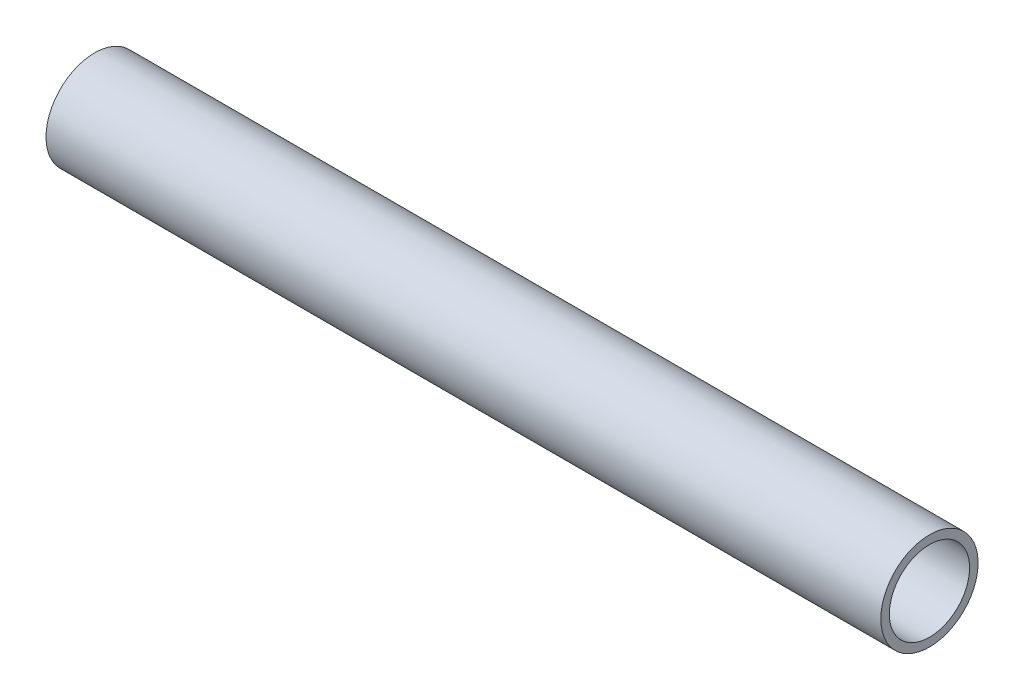
from build123d import *

# Parameters (mm, degrees)
SKETCH1_W = 361.95
SKETCH1_H = 3.683


with BuildPart() as part:
    # Sketch1 → Revolve1 (revolve)
    with BuildSketch(Plane.XY):
        with Locations((180.975, 19.2405)):
            Rectangle(SKETCH1_W, SKETCH1_H)
    revolve(axis=Axis((-17.661090008, 0, 0), (1, 0, 0)))


solid = part.part
